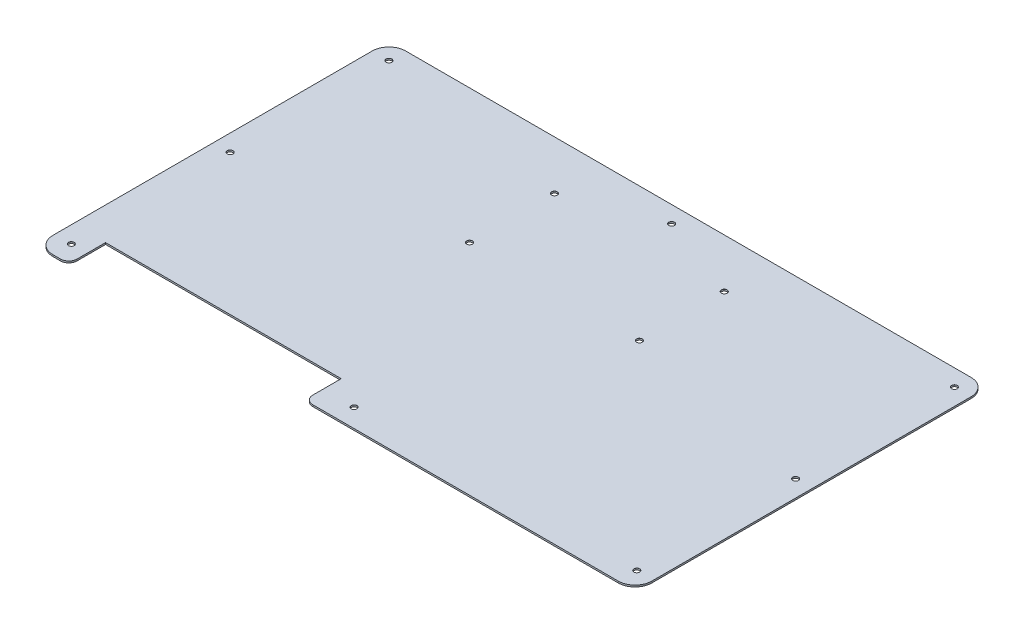
from build123d import *

# Parameters (mm, degrees)
BOSS_EXTRUDE1_DEPTH           = 1
FILLET1_R                     = 10
M3_CLEARANCE_HOLE1_AT_2_COUNT = 2
M3_CLEARANCE_HOLE1_AT_2_PITCH = 95
M3_CLEARANCE_HOLE1_AT_3_COUNT = 2
M3_CLEARANCE_HOLE1_AT_3_PITCH = 95
M3_CLEARANCE_HOLE1_AT_4_COUNT = 2
M3_CLEARANCE_HOLE1_AT_4_PITCH = 193.988783761
M3_CLEARANCE_HOLE1_AT_5_COUNT = 2
M3_CLEARANCE_HOLE1_AT_5_PITCH = 351.356788607
M3_CLEARANCE_HOLE1_AT_6_COUNT = 2
M3_CLEARANCE_HOLE1_AT_6_PITCH = 338.27
M3_CLEARANCE_HOLE1_AT_7_COUNT = 2
M3_CLEARANCE_HOLE1_AT_7_PITCH = 351.356788607
M3_CLEARANCE_HOLE1_AT_8_COUNT = 2
M3_CLEARANCE_HOLE1_AT_8_PITCH = 193.988783761
M3_CLEARANCE_HOLE3_AT_2_COUNT = 2
M3_CLEARANCE_HOLE3_AT_2_PITCH = 50.8
M3_CLEARANCE_HOLE3_AT_3_COUNT = 2
M3_CLEARANCE_HOLE3_AT_3_PITCH = 101.6
M3_CLEARANCE_HOLE3_AT_4_COUNT = 2
M3_CLEARANCE_HOLE3_AT_4_PITCH = 113.592253257
FILLET2_R                     = 5


with BuildPart() as part:
    # Sketch1 → Boss-Extrude1 (new body)
    with BuildSketch(Plane(origin=(0, 0, 0), x_dir=(1, 0, 0), z_dir=(0, 1, 0))):
        Polygon((-159.635, -105.525), (-159.635, -83.525), (-18.635, -83.525), (-18.635, -105.525), (179.135, -105.525), (179.135, 105.525), (-179.135, 105.525), (-179.135, -105.525), align=None)
    extrude(amount=BOSS_EXTRUDE1_DEPTH)

    # Fillet1
    fillet1_edges = [part.edges().sort_by_distance(p)[0] for p in [
        (-179.135, 0.5, 105.525),
        (-179.135, 0.5, -105.525),
        (179.135, 0.5, -105.525),
        (179.135, 0.5, 105.525),
    ]]
    fillet(fillet1_edges, radius=FILLET1_R)

    # Sketch3 → M3 Clearance Hole1 (revolve, cut)
    with BuildSketch(Plane(origin=(169.135, 1, -0.525), x_dir=(0, 0, 1), z_dir=(1, 0, 0))):
        Polygon((0, 0), (0, 1), (1.7, 1), (1.7, 0.025), (1.725, 0), align=None)
    m3_clearance_hole1 = revolve(axis=Axis((169.135, 7.35, -0.525), (0, -1, 0)), mode=Mode.SUBTRACT)

    # M3 Clearance Hole1 at 2: M3 Clearance Hole1 ×2
    with Locations(*[(0, 0, i * M3_CLEARANCE_HOLE1_AT_2_PITCH) for i in range(1, M3_CLEARANCE_HOLE1_AT_2_COUNT)]):
        add(m3_clearance_hole1, mode=Mode.SUBTRACT)

    # M3 Clearance Hole1 at 3: M3 Clearance Hole1 ×2
    with Locations(*[(0, 0, -i * M3_CLEARANCE_HOLE1_AT_3_PITCH) for i in range(1, M3_CLEARANCE_HOLE1_AT_3_COUNT)]):
        add(m3_clearance_hole1, mode=Mode.SUBTRACT)

    # M3 Clearance Hole1 at 4: M3 Clearance Hole1 ×2
    with Locations(*[Vector(-0.871880305, 0, -0.489719035) * (i * M3_CLEARANCE_HOLE1_AT_4_PITCH) for i in range(1, M3_CLEARANCE_HOLE1_AT_4_COUNT)]):
        add(m3_clearance_hole1, mode=Mode.SUBTRACT)

    # M3 Clearance Hole1 at 5: M3 Clearance Hole1 ×2
    with Locations(*[Vector(-0.962753563, 0, -0.270380431) * (i * M3_CLEARANCE_HOLE1_AT_5_PITCH) for i in range(1, M3_CLEARANCE_HOLE1_AT_5_COUNT)]):
        add(m3_clearance_hole1, mode=Mode.SUBTRACT)

    # M3 Clearance Hole1 at 6: M3 Clearance Hole1 ×2
    with Locations(*[(-i * M3_CLEARANCE_HOLE1_AT_6_PITCH, 0, 0) for i in range(1, M3_CLEARANCE_HOLE1_AT_6_COUNT)]):
        add(m3_clearance_hole1, mode=Mode.SUBTRACT)

    # M3 Clearance Hole1 at 7: M3 Clearance Hole1 ×2
    with Locations(*[Vector(-0.962753563, 0, 0.270380431) * (i * M3_CLEARANCE_HOLE1_AT_7_PITCH) for i in range(1, M3_CLEARANCE_HOLE1_AT_7_COUNT)]):
        add(m3_clearance_hole1, mode=Mode.SUBTRACT)

    # M3 Clearance Hole1 at 8: M3 Clearance Hole1 ×2
    with Locations(*[Vector(-0.871880305, 0, 0.489719035) * (i * M3_CLEARANCE_HOLE1_AT_8_PITCH) for i in range(1, M3_CLEARANCE_HOLE1_AT_8_COUNT)]):
        add(m3_clearance_hole1, mode=Mode.SUBTRACT)

    # Sketch5 → M3 Clearance Hole3 (revolve, cut)
    with BuildSketch(Plane(origin=(50.8, 1, -25.4), x_dir=(0, 0, 1), z_dir=(1, 0, 0))):
        Polygon((0, 0), (0, 1), (1.7, 1), (1.7, 0.025), (1.725, 0), align=None)
    m3_clearance_hole3 = revolve(axis=Axis((50.8, 7.35, -25.4), (0, -1, 0)), mode=Mode.SUBTRACT)

    # M3 Clearance Hole3 at 2: M3 Clearance Hole3 ×2
    with Locations(*[(0, 0, -i * M3_CLEARANCE_HOLE3_AT_2_PITCH) for i in range(1, M3_CLEARANCE_HOLE3_AT_2_COUNT)]):
        add(m3_clearance_hole3, mode=Mode.SUBTRACT)

    # M3 Clearance Hole3 at 3: M3 Clearance Hole3 ×2
    with Locations(*[(-i * M3_CLEARANCE_HOLE3_AT_3_PITCH, 0, 0) for i in range(1, M3_CLEARANCE_HOLE3_AT_3_COUNT)]):
        add(m3_clearance_hole3, mode=Mode.SUBTRACT)

    # M3 Clearance Hole3 at 4: M3 Clearance Hole3 ×2
    with Locations(*[Vector(-0.894427191, 0, -0.447213595) * (i * M3_CLEARANCE_HOLE3_AT_4_PITCH) for i in range(1, M3_CLEARANCE_HOLE3_AT_4_COUNT)]):
        add(m3_clearance_hole3, mode=Mode.SUBTRACT)

    # Fillet2
    fillet2_edges = [part.edges().sort_by_distance(p)[0] for p in [
        (-18.635, 0.5, 105.525),
        (-159.635, 0.5, 105.525),
    ]]
    fillet(fillet2_edges, radius=FILLET2_R)


solid = part.part
